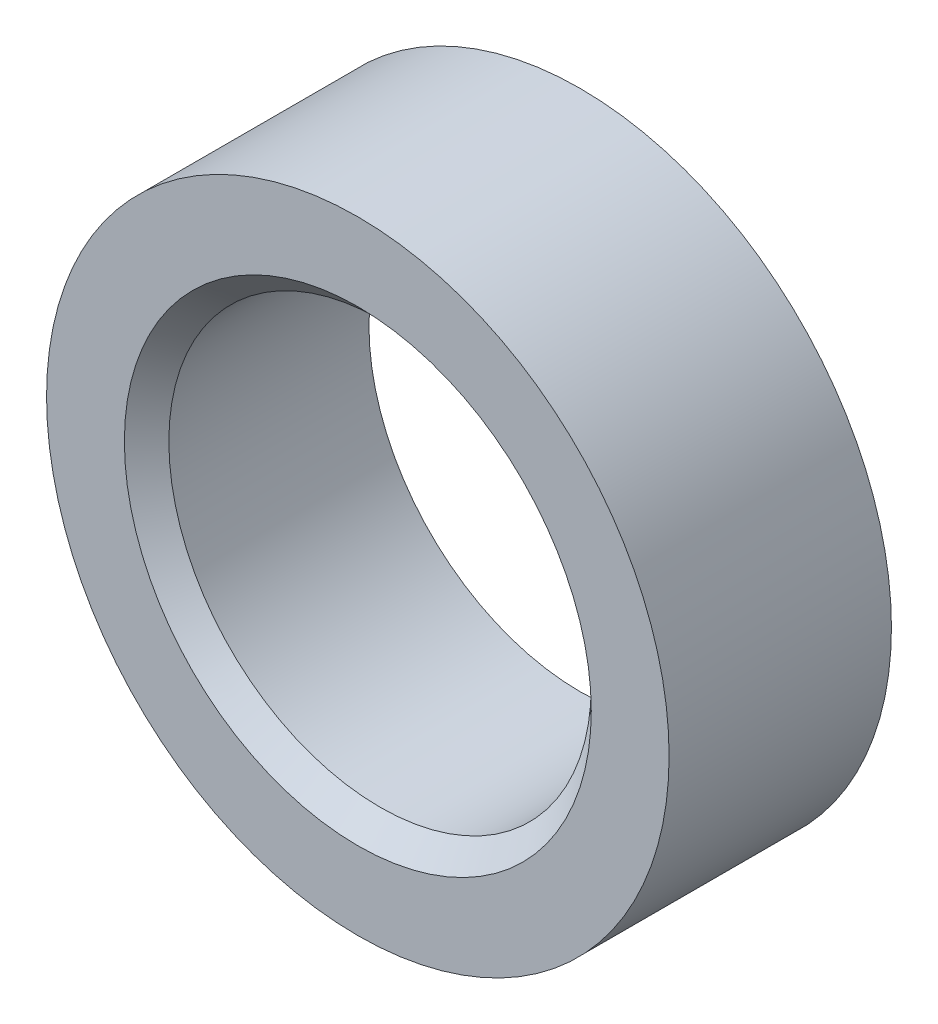
from build123d import *

# Parameters (mm, degrees)
SKETCH1_R           = 14
SKETCH1_R_2         = 9.5
BOSS_EXTRUDE1_DEPTH = 10
CHAMFER1_SIZE       = 1


with BuildPart() as part:
    # Sketch1 → Boss-Extrude1 (new body)
    with BuildSketch(Plane.XY):
        Circle(SKETCH1_R)
        Circle(SKETCH1_R_2, mode=Mode.SUBTRACT)
    extrude(amount=BOSS_EXTRUDE1_DEPTH)

    # Chamfer1
    chamfer1_edges = [part.edges().sort_by_distance(p)[0] for p in [
        (-9.5, 0, 10),
    ]]
    chamfer(chamfer1_edges, length=CHAMFER1_SIZE)


solid = part.part
